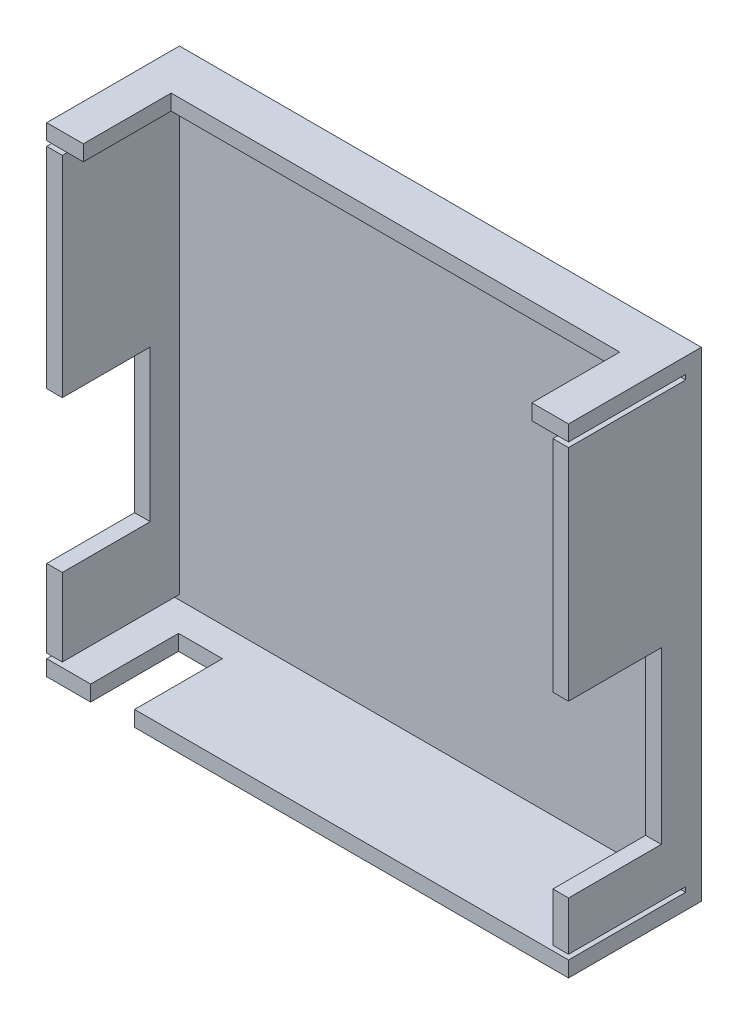
from build123d import *

# Parameters (mm, degrees)
SKETCH1_W           = 106.9
SKETCH1_H           = 98.3
BOSS_EXTRUDE2_DEPTH = 3.2
SKETCH2_W           = 106.9
SKETCH2_H           = 98.3
SKETCH2_W_2         = 100.5
SKETCH2_H_2         = 91.9
BOSS_EXTRUDE3_DEPTH = 24
SKETCH3_W           = 3.2
SKETCH3_H           = 1
CUT_EXTRUDE1_DEPTH  = 24
SKETCH4_W           = 3.2
SKETCH4_H           = 31
CUT_EXTRUDE2_DEPTH  = 18
SKETCH5_W           = 91.9
SKETCH5_H           = 3.2
CUT_EXTRUDE3_DEPTH  = 18
SKETCH6_W           = 3.2
SKETCH6_H           = 34.9
CUT_EXTRUDE4_DEPTH  = 19
SKETCH7_W           = 9
SKETCH7_H           = 3.2
CUT_EXTRUDE5_DEPTH  = 18


with BuildPart() as part:
    # Sketch1 → Boss-Extrude2 (new body)
    with BuildSketch(Plane.XY):
        with Locations((53.45, 49.15)):
            Rectangle(SKETCH1_W, SKETCH1_H)
    extrude(amount=BOSS_EXTRUDE2_DEPTH)

    # Sketch2 → Boss-Extrude3 (add)
    with BuildSketch(Plane.XY.offset(3.2)):
        with Locations((53.45, 49.15)):
            Rectangle(SKETCH2_W, SKETCH2_H)
        with Locations((53.45, 49.15)):
            Rectangle(SKETCH2_W_2, SKETCH2_H_2, mode=Mode.SUBTRACT)
    extrude(amount=BOSS_EXTRUDE3_DEPTH)

    # Sketch3 → Cut-Extrude1 (cut)
    with BuildSketch(Plane.XY.offset(27.2)):
        with Locations((1.6, 94.6)):
            Rectangle(SKETCH3_W, SKETCH3_H)
        with Locations((105.3, 94.6)):
            Rectangle(SKETCH3_W, SKETCH3_H)
        with Locations((105.3, 3.7)):
            Rectangle(SKETCH3_W, SKETCH3_H)
        with Locations((1.6, 3.7)):
            Rectangle(SKETCH3_W, SKETCH3_H)
    extrude(amount=-CUT_EXTRUDE1_DEPTH, mode=Mode.SUBTRACT)

    # Sketch4 → Cut-Extrude2 (cut)
    with BuildSketch(Plane.XY.offset(27.2)):
        with Locations((1.6, 35.6)):
            Rectangle(SKETCH4_W, SKETCH4_H)
    extrude(amount=-CUT_EXTRUDE2_DEPTH, mode=Mode.SUBTRACT)

    # Sketch5 → Cut-Extrude3 (cut)
    with BuildSketch(Plane.XY.offset(27.2)):
        with Locations((53.45, 96.7)):
            Rectangle(SKETCH5_W, SKETCH5_H)
    extrude(amount=-CUT_EXTRUDE3_DEPTH, mode=Mode.SUBTRACT)

    # Sketch6 → Cut-Extrude4 (cut)
    with BuildSketch(Plane.XY.offset(27.2)):
        with Locations((105.3, 31.65)):
            Rectangle(SKETCH6_W, SKETCH6_H)
    extrude(amount=-CUT_EXTRUDE4_DEPTH, mode=Mode.SUBTRACT)

    # Sketch7 → Cut-Extrude5 (cut)
    with BuildSketch(Plane.XY.offset(27.2)):
        with Locations((13.5, 1.6)):
            Rectangle(SKETCH7_W, SKETCH7_H)
    extrude(amount=-CUT_EXTRUDE5_DEPTH, mode=Mode.SUBTRACT)


solid = part.part
